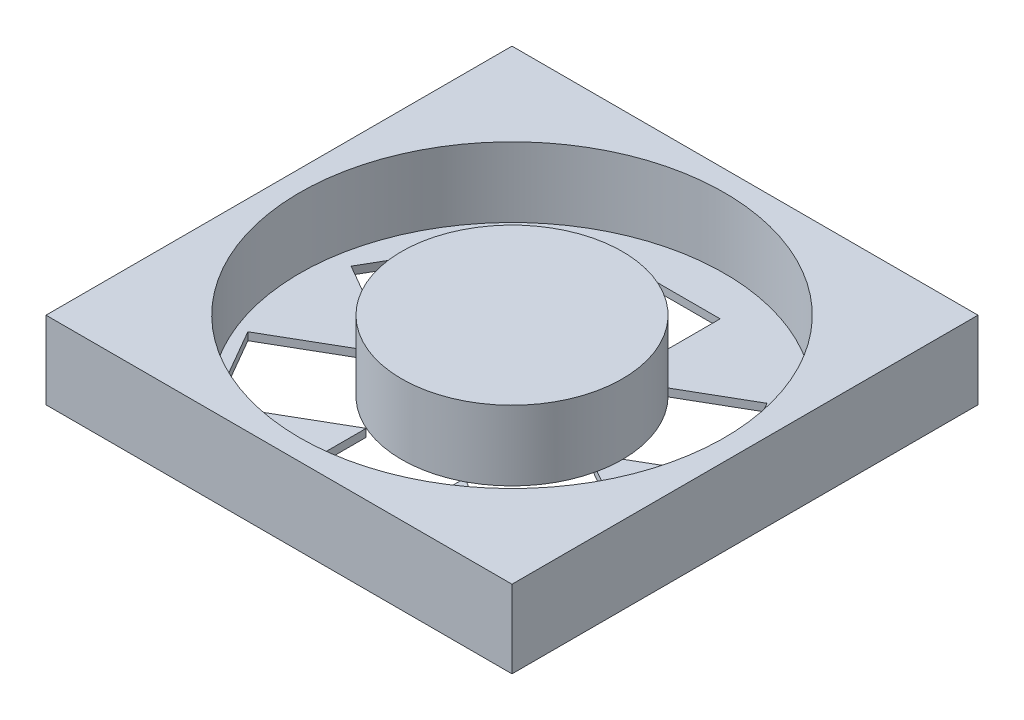
from build123d import *

# Parameters (mm, degrees)
SKETCH1_W           = 60
SKETCH1_H           = 60
BOSS_EXTRUDE1_DEPTH = 10
SKETCH2_R           = 27.339129043
SKETCH2_R_2         = 14.209467058
CUT_EXTRUDE1_DEPTH  = 9
SKETCH3_W           = 11.919517594
SKETCH3_H           = 17.209998666
SKETCH3_W_2         = 11.919517595
CUT_EXTRUDE3_DEPTH  = 1


with BuildPart() as part:
    # Sketch1 → Boss-Extrude1 (new body)
    with BuildSketch(Plane(origin=(0, 0, 0), x_dir=(1, 0, 0), z_dir=(0, 1, 0))):
        with Locations((-3.583333333, -23)):
            Rectangle(SKETCH1_W, SKETCH1_H)
    extrude(amount=BOSS_EXTRUDE1_DEPTH)

    # Sketch2 → Cut-Extrude1 (cut)
    with BuildSketch(Plane(origin=(0, 10, 0), x_dir=(1, 0, 0), z_dir=(0, 1, 0))):
        with Locations((-3.583333333, -23)):
            Circle(SKETCH2_R)
        with Locations((-3.583333333, -23)):
            Circle(SKETCH2_R_2, mode=Mode.SUBTRACT)
    extrude(amount=-CUT_EXTRUDE1_DEPTH, mode=Mode.SUBTRACT)

    # Sketch3 → Cut-Extrude3 (cut)
    with BuildSketch(Plane.XZ):
        Polygon((14.324988363, 42.018967665), (-0.579307681, 33.413968332), (5.380451117, 23.091363294), (20.284747161, 31.696362627), align=None)
        with Locations((-3.392111126, 40.974887496)):
            Rectangle(SKETCH3_W, SKETCH3_H)
        Polygon((19.615469435, 17.733747325), (4.711173391, 26.338746658), (-1.248585407, 16.01614162), (13.655710637, 7.411142287), align=None)
        with Locations((-4.730666578, 9.614445482)):
            Rectangle(SKETCH3_W_2, SKETCH3_H)
        Polygon((-22.447766067, 8.570365313), (-7.543470023, 17.175364646), (-13.50322882, 27.497969684), (-28.407524864, 18.892970351), align=None)
        Polygon((-27.738247138, 32.855585653), (-12.833951095, 24.25058632), (-6.874192297, 34.573191357), (-21.778488341, 43.178190691), align=None)
    extrude(amount=-CUT_EXTRUDE3_DEPTH, mode=Mode.SUBTRACT)


solid = part.part
